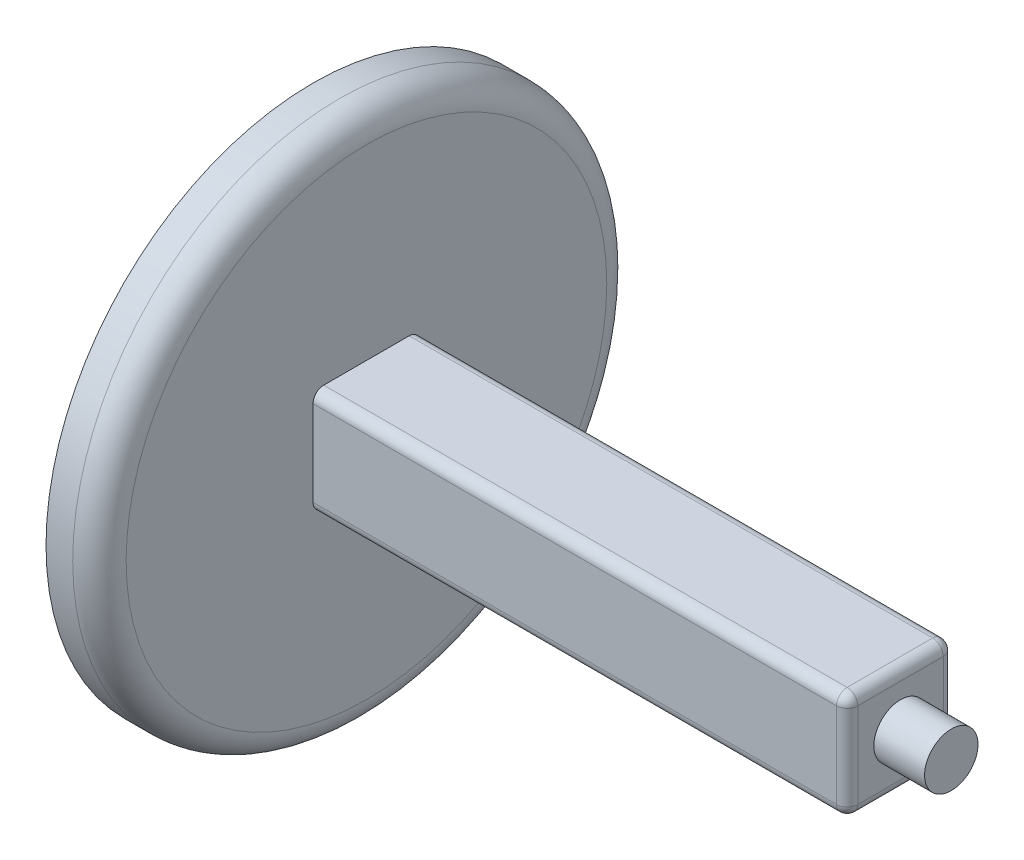
from build123d import *

# Parameters (mm, degrees)
ESQUISSE1_R        = 500
BOSS_EXTRU_1_DEPTH = 100
ESQUISSE2_W        = 200
ESQUISSE2_H        = 200
BOSS_EXTRU_2_DEPTH = 1000
ESQUISSE3_R        = 50
BOSS_EXTRU_3_DEPTH = 95
CONG_1_R           = 50
CONG_2_R           = 20
CONG_3_R           = 20


with BuildPart() as part:
    # Esquisse1 → Boss.-Extru.1 (new body)
    with BuildSketch(Plane(origin=(0, 0, 0), x_dir=(0, 0, -1), z_dir=(1, 0, 0))):
        Circle(ESQUISSE1_R)
    extrude(amount=BOSS_EXTRU_1_DEPTH)

    # Esquisse2 → Boss.-Extru.2 (add)
    with BuildSketch(Plane(origin=(100, 0, 0), x_dir=(0, 0, -1), z_dir=(1, 0, 0))):
        Rectangle(ESQUISSE2_W, ESQUISSE2_H)
    extrude(amount=BOSS_EXTRU_2_DEPTH)

    # Esquisse3 → Boss.-Extru.3 (add)
    with BuildSketch(Plane(origin=(1100, 0, 0), x_dir=(0, 0, -1), z_dir=(1, 0, 0))):
        Circle(ESQUISSE3_R)
    extrude(amount=BOSS_EXTRU_3_DEPTH)

    # Congé1
    cong_1_edges = [part.edges().sort_by_distance(p)[0] for p in [
        (100, 0, 500),
    ]]
    fillet(cong_1_edges, radius=CONG_1_R)

    # Congé2
    cong_2_edges = [part.edges().sort_by_distance(p)[0] for p in [
        (600, -100, -100),
        (600, 100, -100),
        (600, 100, 100),
        (600, -100, 100),
    ]]
    fillet(cong_2_edges, radius=CONG_2_R)

    # Congé3
    cong_3_edges = [part.edges().sort_by_distance(p)[0] for p in [
        (1100, 100, 0),
        (1100, 0, -100),
        (1100, 0, 100),
        (1100, -100, 0),
        (1100, 94.142135624, 94.142135624),
        (1100, -94.142135624, 94.142135624),
        (1100, -94.142135624, -94.142135624),
        (1100, 94.142135624, -94.142135624),
    ]]
    fillet(cong_3_edges, radius=CONG_3_R)


solid = part.part
